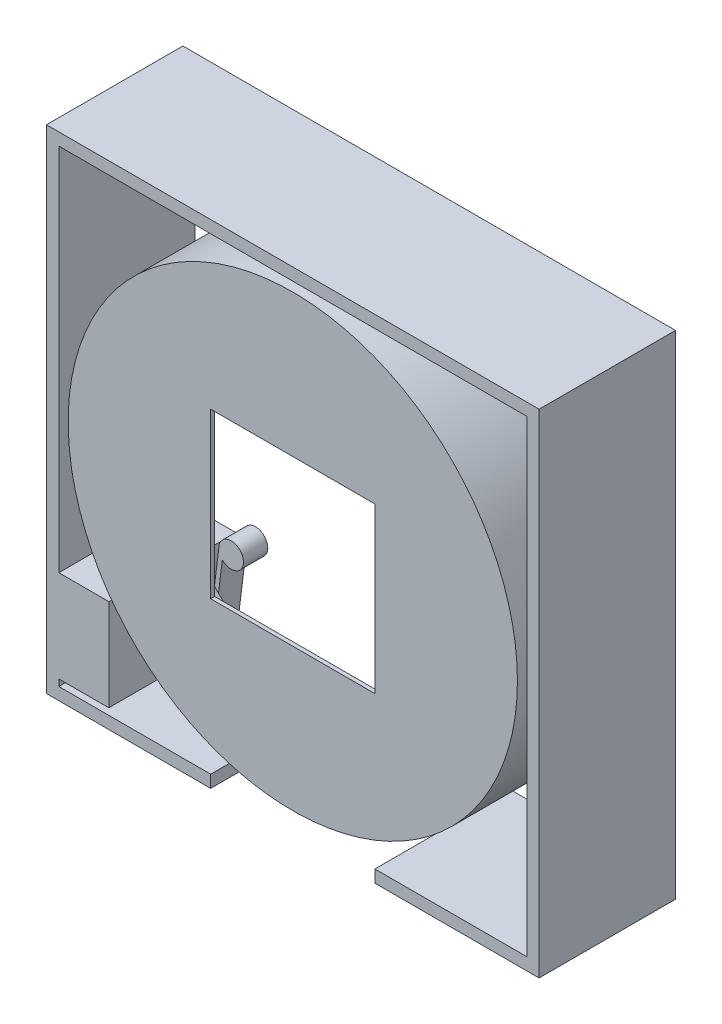
from build123d import *

# Parameters (mm, degrees)
SKETCH3_W           = 31.75
SKETCH3_H           = 31.75
CUT_EXTRUDE1_DEPTH  = 1.762
SKETCH4_W           = 25.4
SKETCH4_H           = 50.8
CUT_EXTRUDE2_DEPTH  = 16.113
BOSS_EXTRUDE2_DEPTH = 26.376923077
BOSS_EXTRUDE3_START = -2.54
SKETCH6_W           = 10.16
SKETCH6_H           = 17.78
SKETCH6_R           = 2.38125
BOSS_EXTRUDE3_DEPTH = 4.699
SKETCH7_W           = 9.677573941
SKETCH7_H           = 17.78
BOSS_EXTRUDE4_DEPTH = 19.137923


with BuildPart() as part:
    # Sketch2 → Revolve1 (revolve)
    with BuildSketch(Plane(origin=(0, 0, 0), x_dir=(1, 0, 0), z_dir=(0, 1, 0))):
        Polygon((0, 0), (43.434, 0), (43.434, 15.875), (42.672, 15.875), (42.672, 0.762), (0, 0.762), align=None)
    revolve(axis=Axis((0, 0, 0), (0, 0, -1)))

    # Sketch3 → Cut-Extrude1 (cut, through all)
    with BuildSketch(Plane(origin=(0, 0, -0.762), x_dir=(-1, 0, 0), z_dir=(0, 0, -1))):
        Rectangle(SKETCH3_W, SKETCH3_H)
    extrude(amount=-CUT_EXTRUDE1_DEPTH, mode=Mode.SUBTRACT)

    # Sketch4 → Cut-Extrude2 (cut, through all)
    with BuildSketch(Plane(origin=(0, 0, -0.762), x_dir=(-1, 0, 0), z_dir=(0, 0, -1))):
        with Locations((0, -25.4)):
            Rectangle(SKETCH4_W, SKETCH4_H)
    extrude(amount=CUT_EXTRUDE2_DEPTH, mode=Mode.SUBTRACT)


with BuildPart() as body_2:
    # Sketch5 → Boss-Extrude2 (new body)
    with BuildSketch(Plane.XY):
        Polygon((45.24375, 45.24375), (-45.24375, 45.24375), (-45.24375, -45.24375), (-15.875, -45.24375), (-15.875, -47.625), (-47.625, -47.625), (-47.625, 47.625), (47.625, 47.625), (47.625, -47.625), (15.875, -47.625), (15.875, -45.24375), (45.24375, -45.24375), align=None)
    extrude(amount=-BOSS_EXTRUDE2_DEPTH)



with BuildPart() as body_3:
    # Sketch6 → Boss-Extrude3 (new body)
    with BuildSketch(Plane(origin=(0, 0, -26.376923077), x_dir=(-1, 0, 0), z_dir=(0, 0, -1)).offset(BOSS_EXTRUDE3_START)):
        with Locations((39.90975, -35.08375)):
            Rectangle(SKETCH6_W, SKETCH6_H)
        with Locations((31.055530123, -25.701278814)):
            Circle(SKETCH6_R)
        with BuildLine():
            Line((32.765891315, -27.358087841), (34.82975, -43.97375))
            Line((34.82975, -43.97375), (34.82975, -36.915766051))
            Line((34.82975, -36.915766051), (33.436780123, -25.701278814))
            ThreePointArc((33.436780123, -25.701278814), (33.262694497, -26.595022058), (32.765891315, -27.358087841))
        make_face()
    extrude(amount=-BOSS_EXTRUDE3_DEPTH)


with BuildPart() as body_2_1:
    add(body_2.part)

    add(body_3.part)  # Boss-Extrude4 merges body 3
    # Sketch7 → Boss-Extrude4 (add)
    with BuildSketch(Plane.XY.offset(-19.137923077)):
        with Locations((-40.40496303, -35.08375)):
            Rectangle(SKETCH7_W, SKETCH7_H)
    extrude(amount=BOSS_EXTRUDE4_DEPTH)


solid = Compound([part.part, body_2_1.part])
